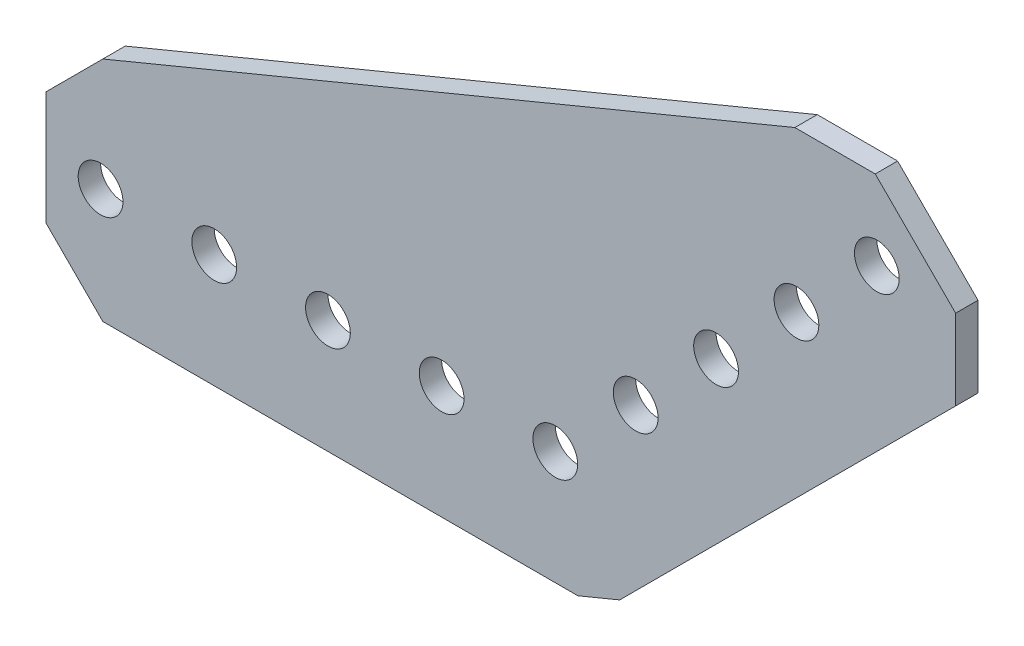
from build123d import *

# Parameters (mm, degrees)
SKETCH1_R           = 2.5
BOSS_EXTRUDE1_DEPTH = 2.5


with BuildPart() as part:
    # Sketch1 → Boss-Extrude1 (new body)
    with BuildSketch(Plane(origin=(0, 0, -1.25), x_dir=(-1, 0, 0), z_dir=(0, 0, -1))):
        Polygon((50.546, 12.7), (-26.761163241, 44.721675483), (-35.741419362, 44.721675483), (-44.721675483, 35.741419362), (-44.721675483, 26.761163241), (-7.193972116, -10.766540126), (-2.526187066, -12.7), (50.546, -12.7), (56.896, -6.35), (56.896, 6.35), align=None)
        with Locations((12.7, 0)):
            Circle(SKETCH1_R, mode=Mode.SUBTRACT)
        with Locations((25.4, 0)):
            Circle(SKETCH1_R, mode=Mode.SUBTRACT)
        Circle(SKETCH1_R, mode=Mode.SUBTRACT)
        with Locations((50.8, 0)):
            Circle(SKETCH1_R, mode=Mode.SUBTRACT)
        with Locations((38.1, 0)):
            Circle(SKETCH1_R, mode=Mode.SUBTRACT)
        with Locations((-35.921024484, 35.921024484)):
            Circle(SKETCH1_R, mode=Mode.SUBTRACT)
        with Locations((-26.940768363, 26.940768363)):
            Circle(SKETCH1_R, mode=Mode.SUBTRACT)
        with Locations((-17.960512242, 17.960512242)):
            Circle(SKETCH1_R, mode=Mode.SUBTRACT)
        with Locations((-8.980256121, 8.980256121)):
            Circle(SKETCH1_R, mode=Mode.SUBTRACT)
    extrude(amount=-BOSS_EXTRUDE1_DEPTH)


solid = part.part
